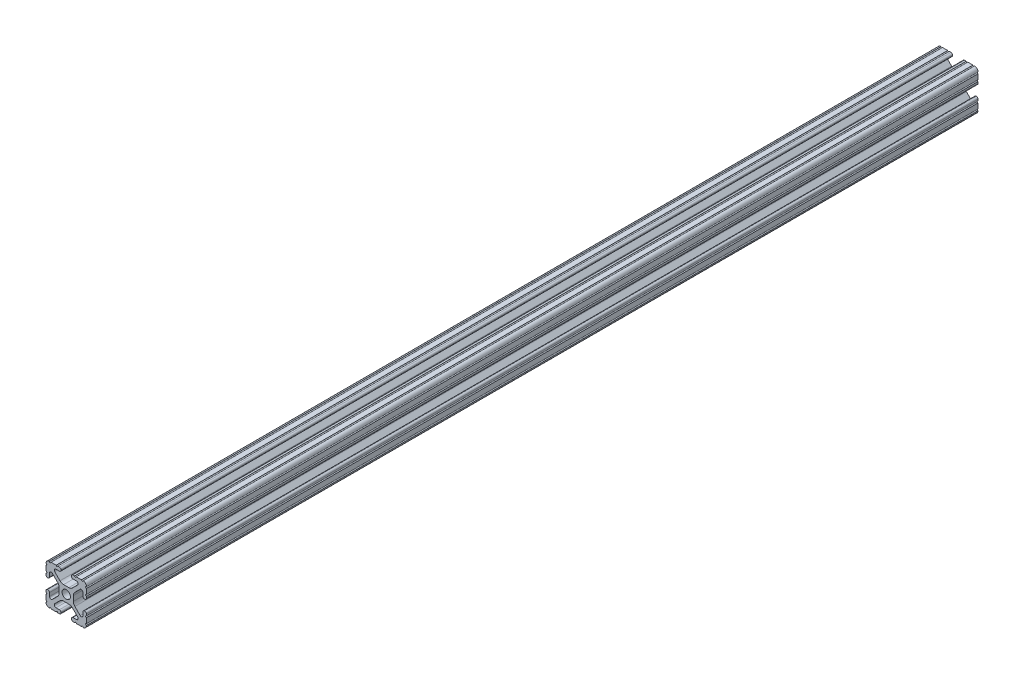
from build123d import *

# Parameters (mm, degrees)
SKETCH16_R                                 = 2.6035
IMPERIAL_AL_EXTRUSION_1010_PROFILE_1_DEPTH = 560


with BuildPart() as part:
    # Sketch16 → Imperial al extrusion 1010 PROFILE(1) (new body)
    with BuildSketch(Plane(origin=(0, 0, 0), x_dir=(-1, 0, 0), z_dir=(0, 0, -1))):
        with BuildLine():
            Line((-1.709253557, -4.4958), (1.709253557, -4.4958))
            ThreePointArc((1.709253557, -4.4958), (2.922935876, -4.736928798), (3.95226937, -5.423689619))
            Line((3.95226937, -5.423689619), (7.179652728, -8.645192207))
            ThreePointArc((7.179652728, -8.645192207), (7.414733441, -9.822812921), (6.41641086, -10.4902))
            Line((6.41641086, -10.4902), (4.28752, -10.4902))
            ThreePointArc((4.28752, -10.4902), (3.545750844, -10.797450844), (3.2385, -11.53922))
            Line((3.2385, -11.53922), (3.2385, -11.65098))
            ThreePointArc((3.2385, -11.65098), (3.545750844, -12.392749156), (4.28752, -12.7))
            Line((4.28752, -12.7), (5.3171344, -12.7))
            ThreePointArc((5.3171344, -12.7), (5.8251344, -12.192), (6.3331344, -12.7))
            Line((6.3331344, -12.7), (9.5504, -12.7))
            ThreePointArc((9.5504, -12.7), (10.058323491, -12.192000006), (10.566399977, -12.699846982))
            ThreePointArc((10.566399977, -12.699846982), (12.082522516, -12.082522516), (12.699846982, -10.566399977))
            ThreePointArc((12.699846982, -10.566399977), (12.192000006, -10.058323491), (12.7, -9.5504))
            Line((12.7, -9.5504), (12.7, -6.3330836))
            ThreePointArc((12.7, -6.3330836), (12.192, -5.8250836), (12.7, -5.3170836))
            Line((12.7, -5.3170836), (12.7, -4.287470133))
            ThreePointArc((12.7, -4.287470133), (12.392749156, -3.545700977), (11.65098, -3.238450133))
            Line((11.65098, -3.238450133), (11.53922, -3.238450133))
            ThreePointArc((11.53922, -3.238450133), (10.797450844, -3.545700977), (10.4902, -4.287470133))
            Line((10.4902, -4.287470133), (10.4902, -6.402089023))
            ThreePointArc((10.4902, -6.402089023), (9.856394933, -7.351113629), (8.736962546, -7.129240479))
            Line((8.736962546, -7.129240479), (5.440484187, -3.838768792))
            ThreePointArc((5.440484187, -3.838768792), (4.75073678, -2.808015636), (4.5085, -1.591658411))
            Line((4.5085, -1.591658411), (4.5085, 1.591658411))
            ThreePointArc((4.5085, 1.591658411), (4.75073678, 2.808015636), (5.440484187, 3.838768792))
            Line((5.440484187, 3.838768792), (8.736962546, 7.129240479))
            ThreePointArc((8.736962546, 7.129240479), (9.856394933, 7.351113629), (10.4902, 6.402089023))
            Line((10.4902, 6.402089023), (10.4902, 4.287470133))
            ThreePointArc((10.4902, 4.287470133), (10.797450844, 3.545700977), (11.53922, 3.238450133))
            Line((11.53922, 3.238450133), (11.65098, 3.238450133))
            ThreePointArc((11.65098, 3.238450133), (12.392749156, 3.545700977), (12.7, 4.287470133))
            Line((12.7, 4.287470133), (12.7, 5.3171344))
            ThreePointArc((12.7, 5.3171344), (12.192, 5.8251344), (12.7, 6.3331344))
            Line((12.7, 6.3331344), (12.7, 9.5504))
            ThreePointArc((12.7, 9.5504), (12.192000006, 10.058323491), (12.699846982, 10.566399977))
            ThreePointArc((12.699846982, 10.566399977), (12.082522516, 12.082522516), (10.566399977, 12.699846982))
            ThreePointArc((10.566399977, 12.699846982), (10.058323491, 12.192000006), (9.5504, 12.7))
            Line((9.5504, 12.7), (6.3330836, 12.7))
            ThreePointArc((6.3330836, 12.7), (5.8250836, 12.192), (5.3170836, 12.7))
            Line((5.3170836, 12.7), (4.2874692, 12.7))
            ThreePointArc((4.2874692, 12.7), (3.545700044, 12.392749156), (3.2384492, 11.65098))
            Line((3.2384492, 11.65098), (3.2384492, 11.53922))
            ThreePointArc((3.2384492, 11.53922), (3.545700044, 10.797450844), (4.2874692, 10.4902))
            Line((4.2874692, 10.4902), (6.476774195, 10.4902))
            ThreePointArc((6.476774195, 10.4902), (7.43216212, 9.851515102), (7.207191475, 8.724540082))
            Line((7.207191475, 8.724540082), (3.900315394, 5.423689619))
            ThreePointArc((3.900315394, 5.423689619), (2.8709819, 4.736928798), (1.657299581, 4.4958))
            Line((1.657299581, 4.4958), (-1.657299581, 4.4958))
            ThreePointArc((-1.657299581, 4.4958), (-2.8709819, 4.736928798), (-3.900315394, 5.423689619))
            Line((-3.900315394, 5.423689619), (-7.207191475, 8.724540082))
            ThreePointArc((-7.207191475, 8.724540082), (-7.43216212, 9.851515102), (-6.476774195, 10.4902))
            Line((-6.476774195, 10.4902), (-4.2874692, 10.4902))
            ThreePointArc((-4.2874692, 10.4902), (-3.545700044, 10.797450844), (-3.2384492, 11.53922))
            Line((-3.2384492, 11.53922), (-3.2384492, 11.65098))
            ThreePointArc((-3.2384492, 11.65098), (-3.545700044, 12.392749156), (-4.2874692, 12.7))
            Line((-4.2874692, 12.7), (-5.3170836, 12.7))
            ThreePointArc((-5.3170836, 12.7), (-5.8250836, 12.192), (-6.3330836, 12.7))
            Line((-6.3330836, 12.7), (-9.5504, 12.7))
            ThreePointArc((-9.5504, 12.7), (-10.058323491, 12.192000006), (-10.566399977, 12.699846982))
            ThreePointArc((-10.566399977, 12.699846982), (-12.082522516, 12.082522516), (-12.699846982, 10.566399977))
            ThreePointArc((-12.699846982, 10.566399977), (-12.192000006, 10.058323491), (-12.7, 9.5504))
            Line((-12.7, 9.5504), (-12.7, 6.3331344))
            ThreePointArc((-12.7, 6.3331344), (-12.192, 5.8251344), (-12.7, 5.3171344))
            Line((-12.7, 5.3171344), (-12.7, 4.287470133))
            ThreePointArc((-12.7, 4.287470133), (-12.392749156, 3.545700977), (-11.65098, 3.238450133))
            Line((-11.65098, 3.238450133), (-11.53922, 3.238450133))
            ThreePointArc((-11.53922, 3.238450133), (-10.797450844, 3.545700977), (-10.4902, 4.287470133))
            Line((-10.4902, 4.287470133), (-10.4902, 6.402089023))
            ThreePointArc((-10.4902, 6.402089023), (-9.856394933, 7.351113629), (-8.736962546, 7.129240479))
            Line((-8.736962546, 7.129240479), (-5.440484187, 3.838768792))
            ThreePointArc((-5.440484187, 3.838768792), (-4.75073678, 2.808015636), (-4.5085, 1.591658411))
            Line((-4.5085, 1.591658411), (-4.5085, -1.591658411))
            ThreePointArc((-4.5085, -1.591658411), (-4.75073678, -2.808015636), (-5.440484187, -3.838768792))
            Line((-5.440484187, -3.838768792), (-8.736962546, -7.129240479))
            ThreePointArc((-8.736962546, -7.129240479), (-9.856394933, -7.351113629), (-10.4902, -6.402089023))
            Line((-10.4902, -6.402089023), (-10.4902, -4.287470133))
            ThreePointArc((-10.4902, -4.287470133), (-10.797450844, -3.545700977), (-11.53922, -3.238450133))
            Line((-11.53922, -3.238450133), (-11.65098, -3.238450133))
            ThreePointArc((-11.65098, -3.238450133), (-12.392749156, -3.545700977), (-12.7, -4.287470133))
            Line((-12.7, -4.287470133), (-12.7, -5.3170836))
            ThreePointArc((-12.7, -5.3170836), (-12.192, -5.8250836), (-12.7, -6.3330836))
            Line((-12.7, -6.3330836), (-12.7, -9.5504))
            ThreePointArc((-12.7, -9.5504), (-12.192000006, -10.058323491), (-12.699846982, -10.566399977))
            ThreePointArc((-12.699846982, -10.566399977), (-12.082522516, -12.082522516), (-10.566399977, -12.699846982))
            ThreePointArc((-10.566399977, -12.699846982), (-10.058323491, -12.192000006), (-9.5504, -12.7))
            Line((-9.5504, -12.7), (-6.3331344, -12.7))
            ThreePointArc((-6.3331344, -12.7), (-5.8251344, -12.192), (-5.3171344, -12.7))
            Line((-5.3171344, -12.7), (-4.28752, -12.7))
            ThreePointArc((-4.28752, -12.7), (-3.545750844, -12.392749156), (-3.2385, -11.65098))
            Line((-3.2385, -11.65098), (-3.2385, -11.53922))
            ThreePointArc((-3.2385, -11.53922), (-3.545750844, -10.797450844), (-4.28752, -10.4902))
            Line((-4.28752, -10.4902), (-6.41641086, -10.4902))
            ThreePointArc((-6.41641086, -10.4902), (-7.414733441, -9.822812921), (-7.179652728, -8.645192207))
            Line((-7.179652728, -8.645192207), (-3.95226937, -5.423689619))
            ThreePointArc((-3.95226937, -5.423689619), (-2.922935876, -4.736928798), (-1.709253557, -4.4958))
        make_face()
        Circle(SKETCH16_R, mode=Mode.SUBTRACT)
    extrude(amount=IMPERIAL_AL_EXTRUSION_1010_PROFILE_1_DEPTH)


solid = part.part
